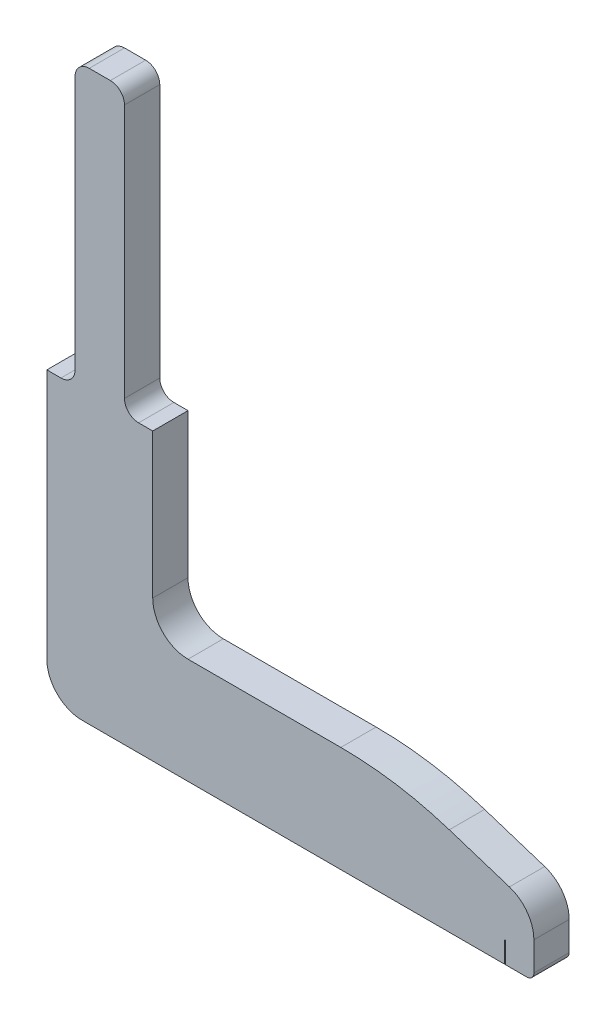
from build123d import *

# Parameters (mm, degrees)
BOSS_EXTRUDE1_DEPTH = 5
SKETCH2_W           = 0.1
SKETCH2_H           = 5
CUT_EXTRUDE2_DEPTH  = 3
FILLET1_R           = 2


with BuildPart() as part:
    # Sketch1 → Boss-Extrude1 (new body)
    with BuildSketch(Plane.XY):
        with BuildLine():
            Line((0, -1), (0, -35.5))
            ThreePointArc((0, -35.5), (1.464466094, -39.035533906), (5, -40.5))
            Line((5, -40.5), (68, -40.5))
            ThreePointArc((68, -40.5), (68.707106781, -40.207106781), (69, -39.5))
            Line((69, -39.5), (69, -35.429996046))
            ThreePointArc((69, -35.429996046), (68.042547906, -32.487580979), (65.53687743, -30.672054499))
            Line((65.53687743, -30.672054499), (57.01873992, -27.920584529))
            ThreePointArc((57.01873992, -27.920584529), (49.429079532, -26.108853154), (41.649965621, -25.5))
            Line((41.649965621, -25.5), (20, -25.5))
            ThreePointArc((20, -25.5), (16.464466094, -24.035533906), (15, -20.5))
            Line((15, -20.5), (15, -1))
            Line((15, -1), (15, 0))
            Line((15, 0), (14, 0))
            Line((14, 0), (11, 0))
            Line((11, 0), (11, 40))
            Line((11, 40), (4, 40))
            Line((4, 40), (4, 0))
            Line((4, 0), (1, 0))
            Line((1, 0), (0, 0))
            Line((0, 0), (0, -1))
        make_face()
    extrude(amount=BOSS_EXTRUDE1_DEPTH)

    # Sketch2 → Cut-Extrude2 (cut)
    with BuildSketch(Plane.XZ.offset(40.5)):
        with Locations((64.9, 2.5)):
            Rectangle(SKETCH2_W, SKETCH2_H)
    extrude(amount=-CUT_EXTRUDE2_DEPTH, mode=Mode.SUBTRACT)

    # Fillet1
    fillet1_edges = [part.edges().sort_by_distance(p)[0] for p in [
        (4, 0, 2.5),
        (4, 40, 2.5),
        (11, 40, 2.5),
        (11, 0, 2.5),
    ]]
    fillet(fillet1_edges, radius=FILLET1_R)


solid = part.part
